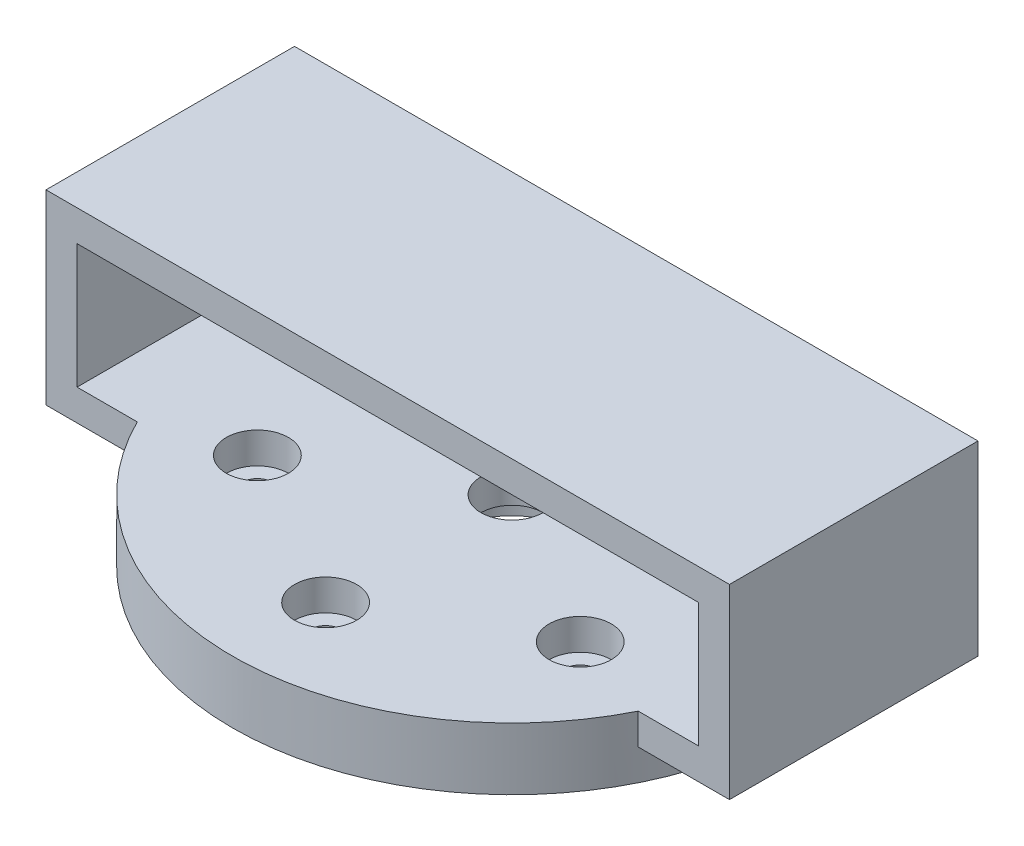
from build123d import *

# Parameters (mm, degrees)
SKETCH1_R                = 45
SKETCH1_R_2              = 2.5
SKETCH1_R_3              = 10
BOSS_EXTRUDE1_DEPTH      = 10
SKETCH2_W                = 110
SKETCH2_H                = 40
BOSS_EXTRUDE2_DEPTH      = 25
BOSS_EXTRUDE2_DEPTH_BACK = 5
SKETCH3_W                = 100
SKETCH3_H                = 20
CUT_EXTRUDE1_DEPTH       = 45
SKETCH4_R                = 5
CUT_EXTRUDE2_DEPTH       = 5


with BuildPart() as part:
    # Sketch1 → Boss-Extrude1 (new body)
    with BuildSketch(Plane(origin=(0, 0, 0), x_dir=(1, 0, 0), z_dir=(0, 1, 0))):
        Circle(SKETCH1_R)
        with Locations((0, 30)):
            Circle(SKETCH1_R_2, mode=Mode.SUBTRACT)
        with Locations((25.980762114, 15)):
            Circle(SKETCH1_R_2, mode=Mode.SUBTRACT)
        with Locations((25.980762114, -15)):
            Circle(SKETCH1_R_2, mode=Mode.SUBTRACT)
        with Locations((0, -30)):
            Circle(SKETCH1_R_2, mode=Mode.SUBTRACT)
        with Locations((-25.980762114, -15)):
            Circle(SKETCH1_R_2, mode=Mode.SUBTRACT)
        with Locations((-25.980762114, 15)):
            Circle(SKETCH1_R_2, mode=Mode.SUBTRACT)
        Circle(SKETCH1_R_3, mode=Mode.SUBTRACT)
    extrude(amount=BOSS_EXTRUDE1_DEPTH)

    # Sketch2 → Boss-Extrude2 (add, two sides)
    with BuildSketch(Plane(origin=(0, 10, 0), x_dir=(1, 0, 0), z_dir=(0, 1, 0))) as boss_extrude2_sk:
        Rectangle(SKETCH2_W, SKETCH2_H)
    extrude(amount=BOSS_EXTRUDE2_DEPTH)
    extrude(boss_extrude2_sk.sketch, amount=-BOSS_EXTRUDE2_DEPTH_BACK)

    # Sketch3 → Cut-Extrude1 (cut)
    with BuildSketch(Plane(origin=(0, 0, -20), x_dir=(-1, 0, 0), z_dir=(0, 0, -1))):
        with Locations((0, 20)):
            Rectangle(SKETCH3_W, SKETCH3_H)
    extrude(amount=-CUT_EXTRUDE1_DEPTH, mode=Mode.SUBTRACT)

    # Sketch4 → Cut-Extrude2 (cut)
    with BuildSketch(Plane(origin=(0, 10, 0), x_dir=(1, 0, 0), z_dir=(0, 1, 0))):
        with Locations((0, 30)):
            Circle(SKETCH4_R)
        with Locations((25.980762114, 15)):
            Circle(SKETCH4_R)
        with Locations((25.980762114, -15)):
            Circle(SKETCH4_R)
        with Locations((0, -30)):
            Circle(SKETCH4_R)
        with Locations((-25.980762114, -15)):
            Circle(SKETCH4_R)
        with Locations((-25.980762114, 15)):
            Circle(SKETCH4_R)
        Circle(SKETCH4_R)
    extrude(amount=-CUT_EXTRUDE2_DEPTH, mode=Mode.SUBTRACT)


solid = part.part
